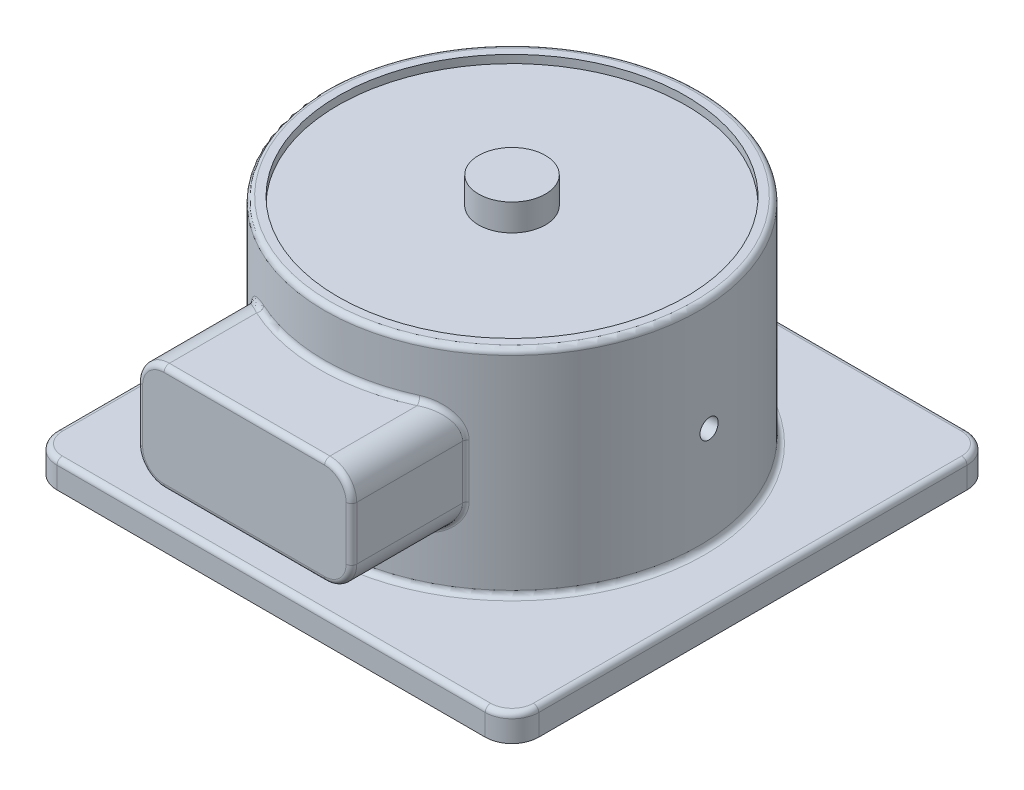
from build123d import *

# Parameters (mm, degrees)
SKETCH1_W           = 180
SKETCH1_H           = 180
BOSS_EXTRUDE1_DEPTH = 10
SKETCH2_R           = 70
BOSS_EXTRUDE2_DEPTH = 80
SKETCH3_W           = 80
SKETCH3_H           = 40
BOSS_EXTRUDE3_DEPTH = 100
CUT_EXTRUDE1_DEPTH  = 3
FILLET1_R           = 10
FILLET2_R           = 2
SKETCH7_R           = 12.5
BOSS_EXTRUDE4_DEPTH = 10


with BuildPart() as part:
    # Sketch1 → Boss-Extrude1 (new body)
    with BuildSketch(Plane(origin=(0, 0, 0), x_dir=(1, 0, 0), z_dir=(0, 1, 0))):
        Rectangle(SKETCH1_W, SKETCH1_H)
    extrude(amount=BOSS_EXTRUDE1_DEPTH)

    # Sketch2 → Boss-Extrude2 (add)
    with BuildSketch(Plane(origin=(0, 10, 0), x_dir=(1, 0, 0), z_dir=(0, 1, 0))):
        with Locations(Location((0, 0, 0), (0, 0, 270))):
            Circle(SKETCH2_R)
    extrude(amount=BOSS_EXTRUDE2_DEPTH)

    # Sketch3 → Boss-Extrude3 (add)
    with BuildSketch(Plane.XY):
        with Locations((0, 50)):
            Rectangle(SKETCH3_W, SKETCH3_H)
    extrude(amount=BOSS_EXTRUDE3_DEPTH)

    # 3DSketch1 → Cut-Extrude1 (cut)
    with BuildSketch(Plane(origin=(0, 90, 65), x_dir=(-0.0019749281305752333, 0, -0.999998049827538), z_dir=(0, -1, 0))):
        with BuildLine():
            add(Edge.make_bspline(
                [(0, 0), (-0.006109401, 3.09779494), (0.425326913, 9.294496524), (2.390353323, 18.402296473), (5.633118591, 27.137209697), (10.087452008, 35.320908574), (15.66244662, 42.786396013), (22.244327614, 49.381310528), (29.698770729, 54.971063258), (37.873644518, 59.441577287), (46.602114808, 62.701617724), (55.706049557, 64.684653106), (64.999654176, 65.350213332), (74.293263267, 64.684715536), (83.397211336, 62.701741308), (92.125703526, 59.441759508), (100.300607343, 54.971300379), (107.755088014, 49.381597779), (114.337013282, 42.786727272), (119.912058141, 35.321278051), (124.366446166, 27.137606225), (127.609271477, 18.402725502), (129.574353967, 9.294898755), (130.221589912, 0), (129.537770415, -9.292278953), (127.536850975, -18.392299757), (124.259666683, -27.114347702), (119.773098852, -35.28042181), (114.16871009, -42.723867507), (107.560875677, -49.292777738), (100.084449379, -54.85309311), (91.892011322, -59.2913378), (83.150754121, -62.516935385), (74.039070779, -64.464057343), (64.742914019, -65.092966493), (55.452001323, -64.390827948), (46.355943159, -62.371971089), (37.640373353, -59.077596989), (29.483160728, -54.5749381), (22.05077882, -48.955884198), (15.494909607, -42.33511441), (9.949343668, -34.84772948), (5.527265783, -26.646596653), (2.348283357, -17.979003931), (0.437364749, -9.036316199), (0.005940915, -3.012363496), (0, 0)],
                knots=[0, 0, 0, 0, 0.022755752, 0.045511504, 0.068267256, 0.091023008, 0.11377876, 0.136534512, 0.159290264, 0.182046016, 0.204801768, 0.22755752, 0.250313272, 0.273069024, 0.295824776, 0.318580528, 0.34133628, 0.364092032, 0.386847784, 0.409603536, 0.432359288, 0.45511504, 0.477870792, 0.500626544, 0.523382296, 0.546138048, 0.5688938, 0.591649552, 0.614405304, 0.637161056, 0.659916808, 0.68267256, 0.705428312, 0.728184064, 0.750939816, 0.773695568, 0.79645132, 0.819207072, 0.841962824, 0.864718576, 0.887474328, 0.91023008, 0.932985832, 0.955741584, 0.977871809, 1, 1, 1, 1], degree=3))
        make_face()
    extrude(amount=CUT_EXTRUDE1_DEPTH, mode=Mode.SUBTRACT)

    # Fillet1
    fillet1_edges = [part.edges().sort_by_distance(p)[0] for p in [
        (-40, 70, 78.722813233),
        (40, 30, 78.722813233),
        (-40, 30, 78.722813233),
        (40, 70, 78.722813233),
        (90, 5, 90),
        (-90, 5, 90),
        (-90, 5, -90),
        (90, 5, -90),
    ]]
    fillet(fillet1_edges, radius=FILLET1_R)

    # Fillet2
    fillet2_edges = [part.edges().sort_by_distance(p)[0] for p in [
        (0, 10, -70),
        (0, 90, -70),
        (15.375488216, 30, 68.290514437),
        (0, 30, 100),
        (-40, 50, 57.445626465),
        (-40, 50, 100),
        (40, 50, 100),
        (0, 70, 100),
        (-37.071067812, 67.071067812, 100),
        (37.071067812, 67.071067812, 100),
        (37.071067812, 32.928932188, 100),
        (-37.071067812, 32.928932188, 100),
        (40, 50, 57.445626465),
        (15.375488216, 70, 68.290514437),
        (90, 10, 0),
        (0, 10, 90),
        (0, 10, -90),
        (-90, 10, 0),
        (-87.071067812, 10, 87.071067812),
        (-87.071067812, 10, -87.071067812),
        (87.071067812, 10, -87.071067812),
        (87.071067812, 10, 87.071067812),
        (-36.872641972, 32.735924536, 59.501330019),
        (36.872641972, 32.735924536, 59.501330019),
        (36.872641972, 67.264075464, 59.501330019),
        (-36.872641975, 67.264075467, 59.501330017),
    ]]
    fillet(fillet2_edges, radius=FILLET2_R)

    # Sketch6 → 1/16 NPT Tapped Hole1 (revolve, cut)
    with BuildSketch(Plane(origin=(69.894586304, 47.911002141, -3.840156953), x_dir=(-0.054859385045466544, 0, -0.9984940900538337), z_dir=(0, 1, 0))):
        Polygon((0, 0), (0, 6.946685027), (3.0734, 5.1), (3.0734, 8), (3.364805487, 8), (3.6043362, 0), align=None)
    revolve(axis=Axis((76.235023776, 47.911002141, -4.188514048), (-0.9984940900538337, 0, 0.05485938504546654)), mode=Mode.SUBTRACT)

    # Sketch7 → Boss-Extrude4 (add)
    with BuildSketch(Plane(origin=(0, 87, 0), x_dir=(1, 0, 0), z_dir=(0, 1, 0))):
        with Locations(Location((0, 0, 0), (0, 0, 270))):
            Circle(SKETCH7_R)
    extrude(amount=BOSS_EXTRUDE4_DEPTH)


solid = part.part
